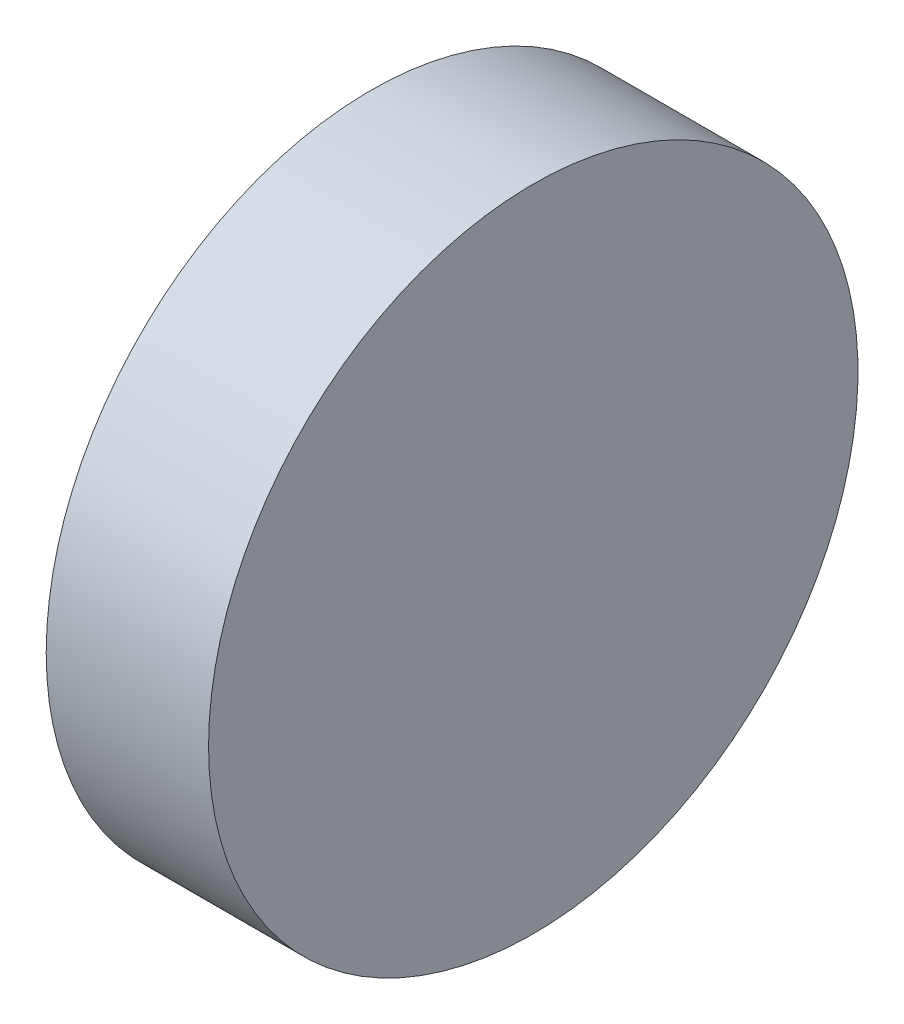
from build123d import *

# Parameters (mm, degrees)
SKETCH_1_W = 12.7
SKETCH_1_H = 25.4


with BuildPart() as part:
    # 草图1 → 旋转1 (revolve)
    with BuildSketch(Plane.XY, mode=Mode.PRIVATE) as revolve_1_sk:
        with Locations((525.798705786, 167.286358698)):
            Rectangle(SKETCH_1_W, SKETCH_1_H)
    revolve(revolve_1_sk.sketch.rotate(Axis((508.001603985, 154.586358698, 0), (1, 0, 0)), 90), axis=Axis((508.001603985, 154.586358698, 0), (1, 0, 0)))  # turned: the seam where the file's is


solid = part.part
